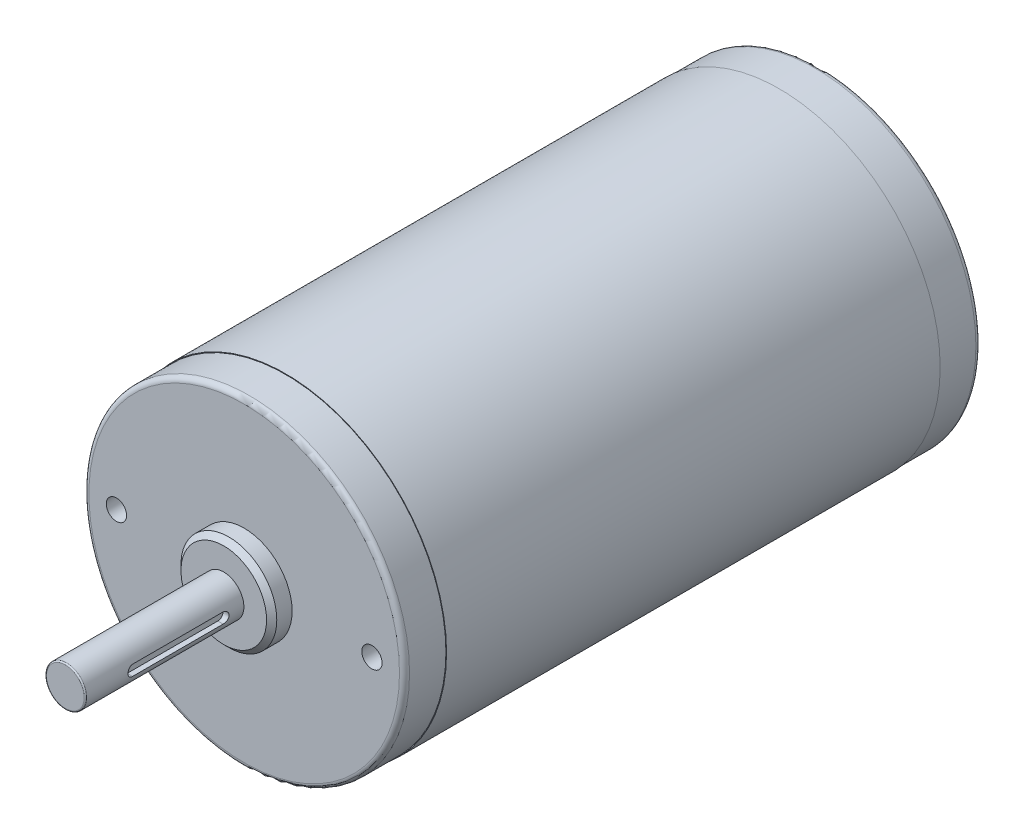
from build123d import *

# Parameters (mm, degrees)
SKETCH1_W                       = 32.004
SKETCH1_H                       = 98.1456
SKETCH2_R                       = 31.877
BOSS_EXTRUDE1_DEPTH             = 8.2296
SKETCH3_R                       = 15.0368
BOSS_EXTRUDE2_DEPTH             = 4.7625
SKETCH4_R                       = 31.877
BOSS_EXTRUDE3_DEPTH             = 8.2296
SKETCH5_R                       = 9.525
BOSS_EXTRUDE4_DEPTH             = 4.064
SKETCH6_R                       = 4
BOSS_EXTRUDE5_DEPTH             = 31.5
CUT_EXTRUDE1_REACH              = 31.204
F_21_0_159_DIAMETER_HOLE1_D     = 4.0386
F_21_0_159_DIAMETER_HOLE1_DEPTH = 13.6144
F_21_0_159_DIAMETER_HOLE1_TIP   = 1.213317848
CHAMFER1_SIZE2                  = 1.016
CHAMFER1_SIZE                   = 1.015999998
FILLET1_R                       = 0.254
FILLET2_R                       = 1


with BuildPart() as part:
    # Sketch1 → Revolve1 (revolve)
    with BuildSketch(Plane.XZ.offset(-109.2962)):
        with Locations((51.562, -38.2524)):
            Rectangle(SKETCH1_W, SKETCH1_H)
    revolve(axis=Axis((35.56, 109.2962, 10.8204), (0, 0, -1)))

    # Sketch2 → Boss-Extrude1 (add)
    with BuildSketch(Plane(origin=(0, 0, -87.3252), x_dir=(-1, 0, 0), z_dir=(0, 0, -1))):
        with Locations((-35.56, 109.2962)):
            Circle(SKETCH2_R)
    extrude(amount=BOSS_EXTRUDE1_DEPTH)

    # Sketch3 → Boss-Extrude2 (add)
    with BuildSketch(Plane(origin=(0, 0, -95.5548), x_dir=(-1, 0, 0), z_dir=(0, 0, -1))):
        with Locations((-35.56, 109.2962)):
            Circle(SKETCH3_R)
    extrude(amount=BOSS_EXTRUDE2_DEPTH)

    # Sketch4 → Boss-Extrude3 (add)
    with BuildSketch(Plane.XY.offset(10.8204)):
        with Locations((35.56, 109.2962)):
            Circle(SKETCH4_R)
    extrude(amount=BOSS_EXTRUDE3_DEPTH)

    # Sketch5 → Boss-Extrude4 (add)
    with BuildSketch(Plane.XY.offset(19.05)):
        with Locations((35.56, 109.2962)):
            Circle(SKETCH5_R)
    extrude(amount=BOSS_EXTRUDE4_DEPTH)

    # Sketch6 → Boss-Extrude5 (add)
    with BuildSketch(Plane.XY.offset(23.114)):
        with Locations((35.56, 109.2962)):
            Circle(SKETCH6_R)
    extrude(amount=BOSS_EXTRUDE5_DEPTH)

    # Sketch7 → Cut-Extrude1 (cut, up to next)
    with BuildSketch(Plane(origin=(38.36, 0, 0), x_dir=(0, -1, 0), z_dir=(-1, 0, 0)), mode=Mode.PRIVATE) as cut_extrude1_sk1:
        with BuildLine():
            Line((-108.2462, 27.1), (-108.2462, 45.1))
            ThreePointArc((-108.2462, 45.1), (-109.2962, 46.15), (-110.3462, 45.1))
            Line((-110.3462, 45.1), (-110.3462, 27.1))
            ThreePointArc((-110.3462, 27.1), (-109.2962, 26.05), (-108.2462, 27.1))
        make_face()
    cut_extrude1_tool1 = extrude(cut_extrude1_sk1.sketch, amount=-CUT_EXTRUDE1_REACH, mode=Mode.PRIVATE) & part.part
    add(cut_extrude1_tool1.solids().sort_by_distance((38.36, 109.2962, 36.1))[0], mode=Mode.SUBTRACT)

    # Sketch8 → Revolve2 (revolve)
    with BuildSketch(Plane.XZ.offset(-120.503559639)):
        Polygon((58.485090683, -95.5548), (54.167090681, -95.5548), (54.167090681, -97.802699998), (56.285090681, -97.802699998), (58.485090683, -95.602699996), align=None)
    revolve(axis=Axis((54.167090681, 120.503559639, -95.5548), (0, 0, -1)))

    # Sketch9 → Revolve3 (revolve)
    with BuildSketch(Plane.XZ.offset(-127.903290683)):
        Polygon((51.085359639, -95.5548), (46.767359637, -95.5548), (46.767359637, -97.802699998), (48.885359637, -97.802699998), (51.085359639, -95.602699996), align=None)
    revolve(axis=Axis((46.767359637, 127.903290683, -95.5548), (0, 0, -1)))

    # #21 (0.159) Diameter Hole1
    with Locations(Plane.XY.offset(19.05)):
        with Locations((10.16, 109.2962), (60.96, 109.2962)):
            Hole(F_21_0_159_DIAMETER_HOLE1_D / 2, depth=F_21_0_159_DIAMETER_HOLE1_DEPTH)
            with Locations((0, 0, -(F_21_0_159_DIAMETER_HOLE1_DEPTH + F_21_0_159_DIAMETER_HOLE1_TIP / 2))):  # 118° drill point
                Cone(0, F_21_0_159_DIAMETER_HOLE1_D / 2, F_21_0_159_DIAMETER_HOLE1_TIP, mode=Mode.SUBTRACT)

    # Chamfer1
    chamfer1_edges = [part.edges().sort_by_distance(p)[0] for p in [
        (26.035, 109.2962, 23.114),
    ]]
    chamfer(chamfer1_edges, length=CHAMFER1_SIZE, length2=CHAMFER1_SIZE2)

    # Fillet1
    fillet1_edges = [part.edges().sort_by_distance(p)[0] for p in [
        (31.56, 109.2962, 54.614),
    ]]
    fillet(fillet1_edges, radius=FILLET1_R)

    # Fillet2
    fillet2_edges = [part.edges().sort_by_distance(p)[0] for p in [
        (50.5968, 109.2962, -100.3173),
        (3.683, 109.2962, 19.05),
        (67.437, 109.2962, -95.5548),
    ]]
    fillet(fillet2_edges, radius=FILLET2_R)


solid = part.part
